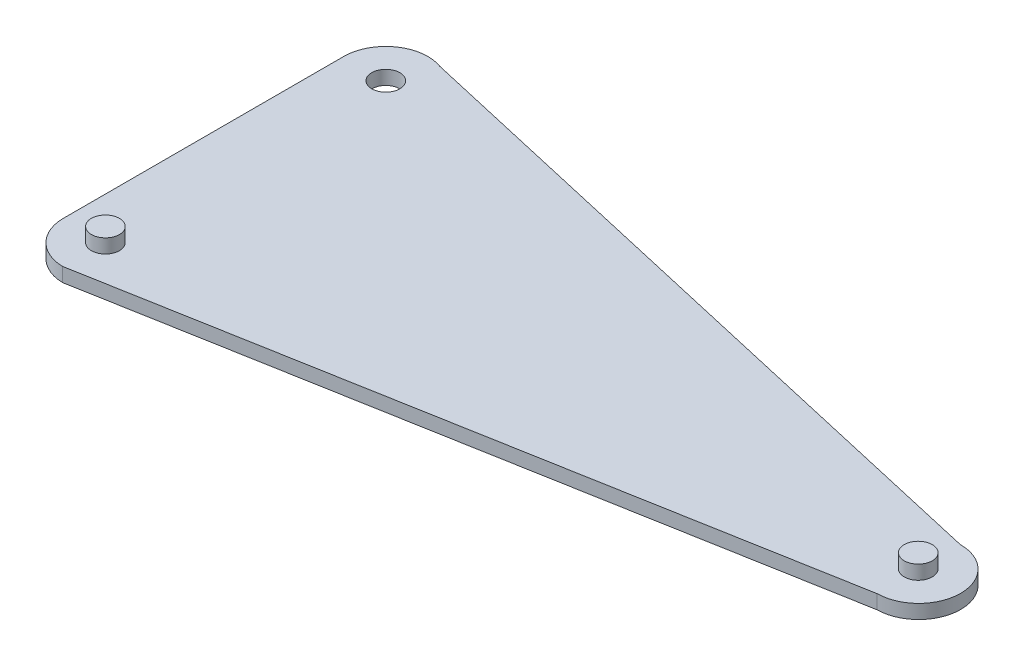
from build123d import *

# Parameters (mm, degrees)
SKETCH1_R           = 1
BOSS_EXTRUDE5_DEPTH = 1
SKETCH3_R           = 1
BOSS_EXTRUDE6_DEPTH = 0.5
SKETCH5_R           = 1
BOSS_EXTRUDE8_DEPTH = 1
SKETCH6_R           = 1
BOSS_EXTRUDE9_DEPTH = 1


with BuildPart() as part:
    # Sketch1 → Boss-Extrude5 (new body)
    with BuildSketch(Plane(origin=(0, 0, 0), x_dir=(1, 0, 0), z_dir=(0, 1, 0))):
        with BuildLine():
            Line((-47.682880055, 11.164224632), (-47.682880055, -8.835775368))
            ThreePointArc((-47.682880055, -8.835775368), (-46.828715239, -10.932294236), (-44.752619147, -11.834964669))
            Line((-44.752619147, -11.834964669), (4.512839673, -2.999578636))
            ThreePointArc((4.512839673, -2.999578636), (7.487489348, 0.025350325), (4.462560387, 3))
            Line((4.462560387, 3), (-43.657583095, 13.983580257))
            ThreePointArc((-43.657583095, 13.983580257), (-46.403942099, 13.621447747), (-47.682880055, 11.164224632))
        make_face()
        with Locations((-44.682880055, 11.164224632)):
            Circle(SKETCH1_R, mode=Mode.SUBTRACT)
        with Locations((-44.682880055, -8.835775368)):
            Circle(SKETCH1_R, mode=Mode.SUBTRACT)
        with Locations((4.462560387, 0)):
            Circle(SKETCH1_R, mode=Mode.SUBTRACT)
    extrude(amount=BOSS_EXTRUDE5_DEPTH)

    # Sketch3 → Boss-Extrude6 (add, symmetric)
    with BuildSketch(Plane(origin=(0, 1, 0), x_dir=(1, 0, 0), z_dir=(0, 1, 0))):
        with Locations((4.462560387, 0)):
            Circle(SKETCH3_R)
    extrude(amount=BOSS_EXTRUDE6_DEPTH, both=True)

    # Sketch5 → Boss-Extrude8 (add)
    with BuildSketch(Plane(origin=(0, 1, 0), x_dir=(1, 0, 0), z_dir=(0, 1, 0))):
        with Locations((4.462560387, 0)):
            Circle(SKETCH5_R)
    extrude(amount=BOSS_EXTRUDE8_DEPTH)

    # Sketch6 → Boss-Extrude9 (add, symmetric)
    with BuildSketch(Plane(origin=(0, 1, 0), x_dir=(1, 0, 0), z_dir=(0, 1, 0))):
        with Locations((-44.682880055, -8.835775368)):
            Circle(SKETCH6_R)
    extrude(amount=BOSS_EXTRUDE9_DEPTH, both=True)


solid = part.part
